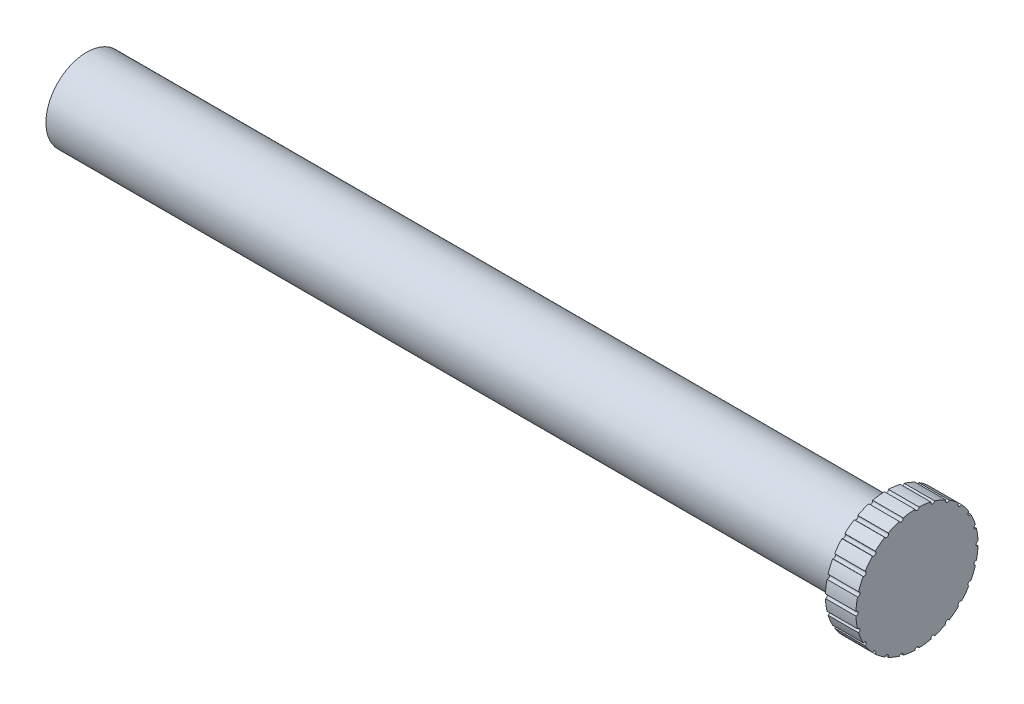
from build123d import *

# Parameters (mm, degrees)
SKETCH1_R           = 4
BOSS_EXTRUDE1_DEPTH = 78.63
SKETCH2_R           = 6
BOSS_EXTRUDE2_DEPTH = 3
SKETCH3_R           = 0.2
CUT_EXTRUDE1_DEPTH  = 3
CIRPATTERN1_COUNT   = 24


with BuildPart() as part:
    # Sketch1 → Boss-Extrude1 (new body)
    with BuildSketch(Plane(origin=(0, 0, 0), x_dir=(0, 0, -1), z_dir=(1, 0, 0))):
        Circle(SKETCH1_R)
    extrude(amount=BOSS_EXTRUDE1_DEPTH)

    # Sketch2 → Boss-Extrude2 (add)
    with BuildSketch(Plane(origin=(78.63, 0, 0), x_dir=(0, 0, -1), z_dir=(1, 0, 0))):
        Circle(SKETCH2_R)
    extrude(amount=BOSS_EXTRUDE2_DEPTH)

    # Sketch3 → Cut-Extrude1 (cut)
    with BuildSketch(Plane(origin=(81.63, 0, 0), x_dir=(0, 0, -1), z_dir=(1, 0, 0))):
        with Locations((-6, 0)):
            Circle(SKETCH3_R)
    cut_extrude1 = extrude(amount=-CUT_EXTRUDE1_DEPTH, mode=Mode.SUBTRACT)

    # CirPattern1: Cut-Extrude1 ×24 about axis
    cirpattern1_axis = Axis((0, 0, 0), (1, 0, 0))
    for i in range(1, CIRPATTERN1_COUNT):
        add(cut_extrude1.rotate(cirpattern1_axis, i * 360 / CIRPATTERN1_COUNT), mode=Mode.SUBTRACT)


solid = part.part
